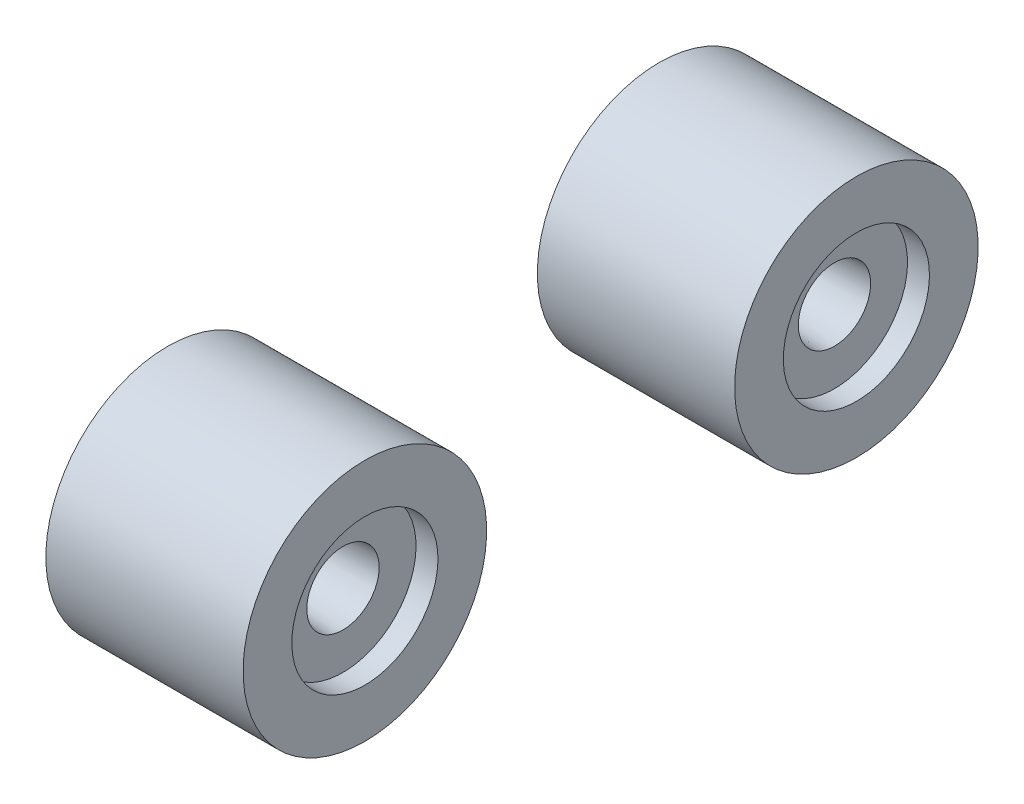
from build123d import *

# Parameters (mm, degrees)
SKETCH1_W           = 18
SKETCH1_H           = 12.5
SKETCH2_R           = 3.71375
CUT_EXTRUDE1_DEPTH  = 7.5725
CUT_EXTRUDE1_TAPER  = 3
SKETCH4_R           = 3.71375
CUT_EXTRUDE2_DEPTH  = 7.0725
CUT_EXTRUDE2_TAPER  = 3
SKETCH5_R           = 12.5
SKETCH5_R_2         = 7.5
BOSS_EXTRUDE1_DEPTH = 2.25


with BuildPart() as part:
    # Sketch1 → Revolve1 (revolve)
    with BuildSketch(Plane.XY):
        with Locations((17.255, 6.25)):
            Rectangle(SKETCH1_W, SKETCH1_H)
    revolve(axis=Axis((8.255, 0, 0), (1, 0, 0)))

    # Sketch2 → Cut-Extrude1 (cut)
    with BuildSketch(Plane.ZY.offset(-8.255)):
        Circle(SKETCH2_R)
    extrude(amount=-CUT_EXTRUDE1_DEPTH, taper=CUT_EXTRUDE1_TAPER, mode=Mode.SUBTRACT)

    # Sketch4 → Cut-Extrude2 (cut)
    with BuildSketch(Plane(origin=(26.255, 0, 0), x_dir=(0, 0, -1), z_dir=(1, 0, 0))):
        Circle(SKETCH4_R)
    extrude(amount=-CUT_EXTRUDE2_DEPTH, taper=CUT_EXTRUDE2_TAPER, mode=Mode.SUBTRACT)


with BuildPart() as body_2:
    # Body-Move/Copy1: copy of part
    add(part.part.moved(Location((0, 0, 50.452769062))))


with BuildPart() as part_1:
    add(part.part)

    # Sketch5 → Boss-Extrude1 (add)
    with BuildSketch(Plane(origin=(26.255, 0, 0), x_dir=(0, 0, -1), z_dir=(1, 0, 0))):
        Circle(SKETCH5_R)
        Circle(SKETCH5_R_2, mode=Mode.SUBTRACT)
        with Locations((-50.452769062, 0)):
            Circle(SKETCH5_R)
        with Locations((-50.452769062, 0)):
            Circle(SKETCH5_R_2, mode=Mode.SUBTRACT)
    extrude(amount=BOSS_EXTRUDE1_DEPTH)


with BuildPart() as body_2_1:
    add(body_2.part)

    # Combine1: union part
    add(part_1.part)


solid = body_2_1.part
